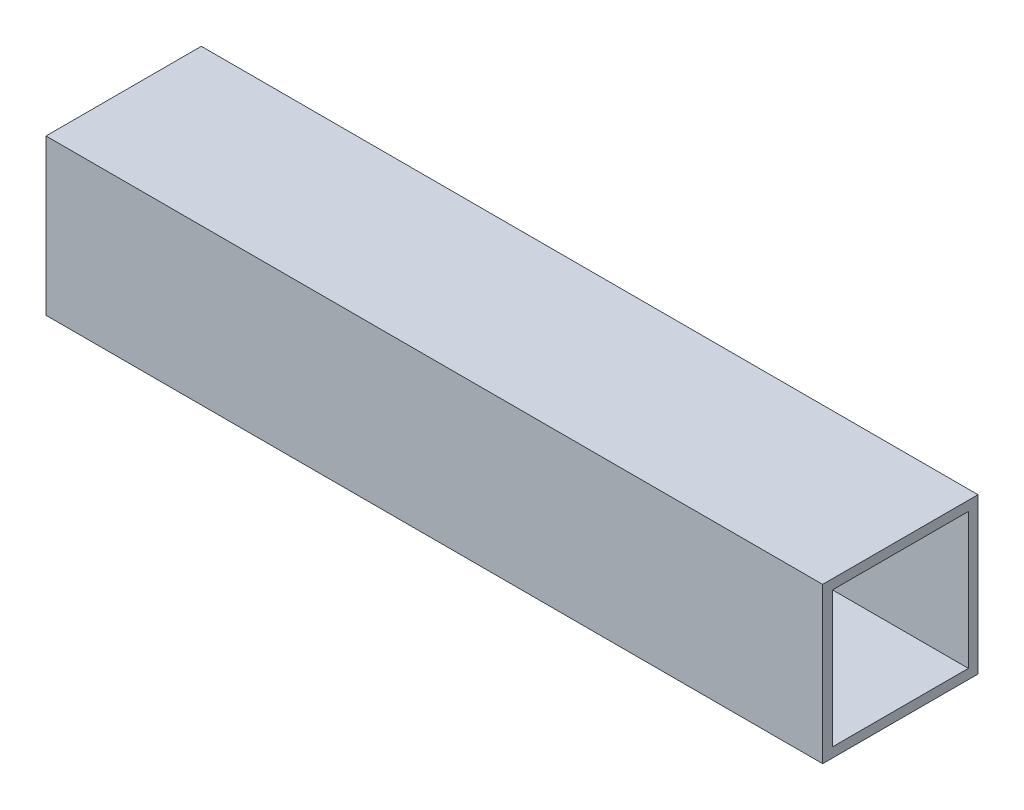
from build123d import *

# Parameters (mm, degrees)
SKETCH2_W           = 50.8
SKETCH2_H           = 50.8
SKETCH2_W_2         = 44.4881
SKETCH2_H_2         = 44.45
BOSS_EXTRUDE1_DEPTH = 254


with BuildPart() as part:
    # Sketch2 → Boss-Extrude1 (new body)
    with BuildSketch(Plane(origin=(0, 0, 0), x_dir=(0, 0, -1), z_dir=(1, 0, 0))):
        with Locations((25.4, 25.4)):
            Rectangle(SKETCH2_W, SKETCH2_H)
        with Locations((25.41905, 25.4)):
            Rectangle(SKETCH2_W_2, SKETCH2_H_2, mode=Mode.SUBTRACT)
    extrude(amount=BOSS_EXTRUDE1_DEPTH)


solid = part.part
